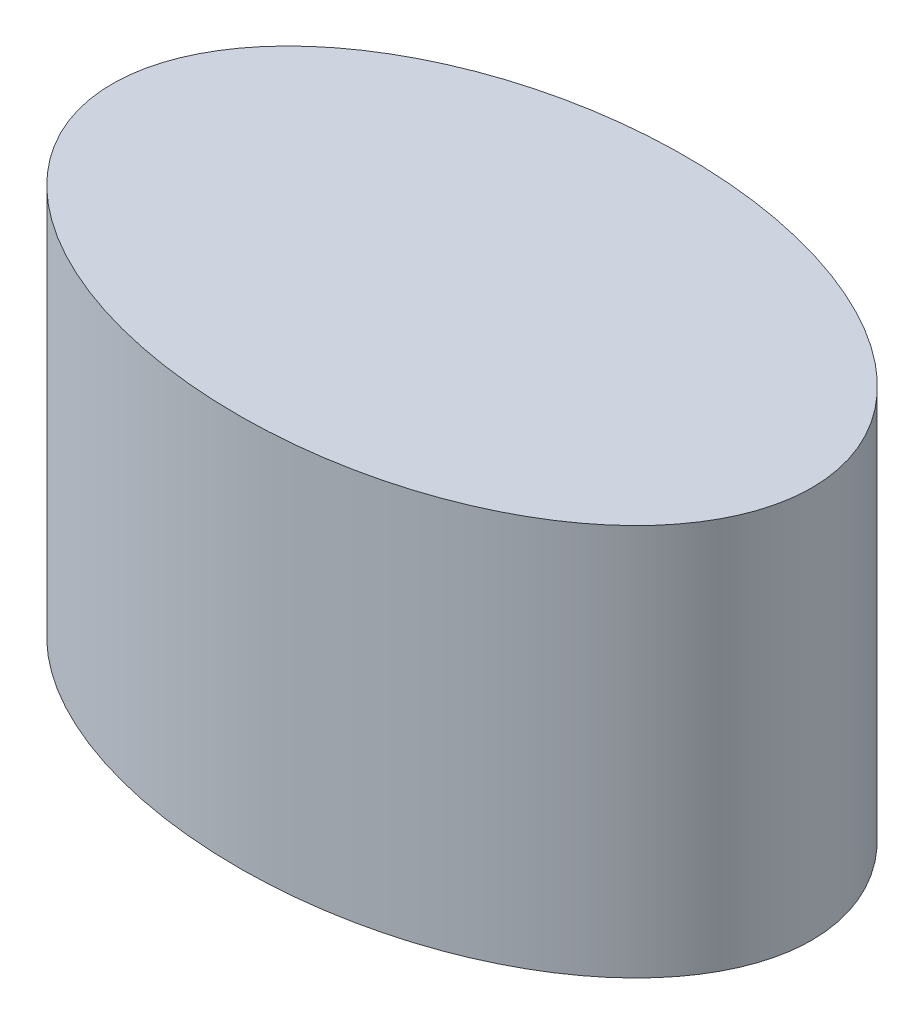
from build123d import *

# Parameters (mm, degrees)
SKETCH_1_RX     = 25
SKETCH_1_RY     = 16
EXTRUDE_1_DEPTH = 28


with BuildPart() as part:
    # 草圖1 → 填料-伸長1 (new body)
    with BuildSketch(Plane(origin=(0, 0, 0), x_dir=(1, 0, 0), z_dir=(0, 1, 0))):
        with Locations((0, 0)):
            Ellipse(SKETCH_1_RX, SKETCH_1_RY)
    extrude(amount=EXTRUDE_1_DEPTH)


solid = part.part
